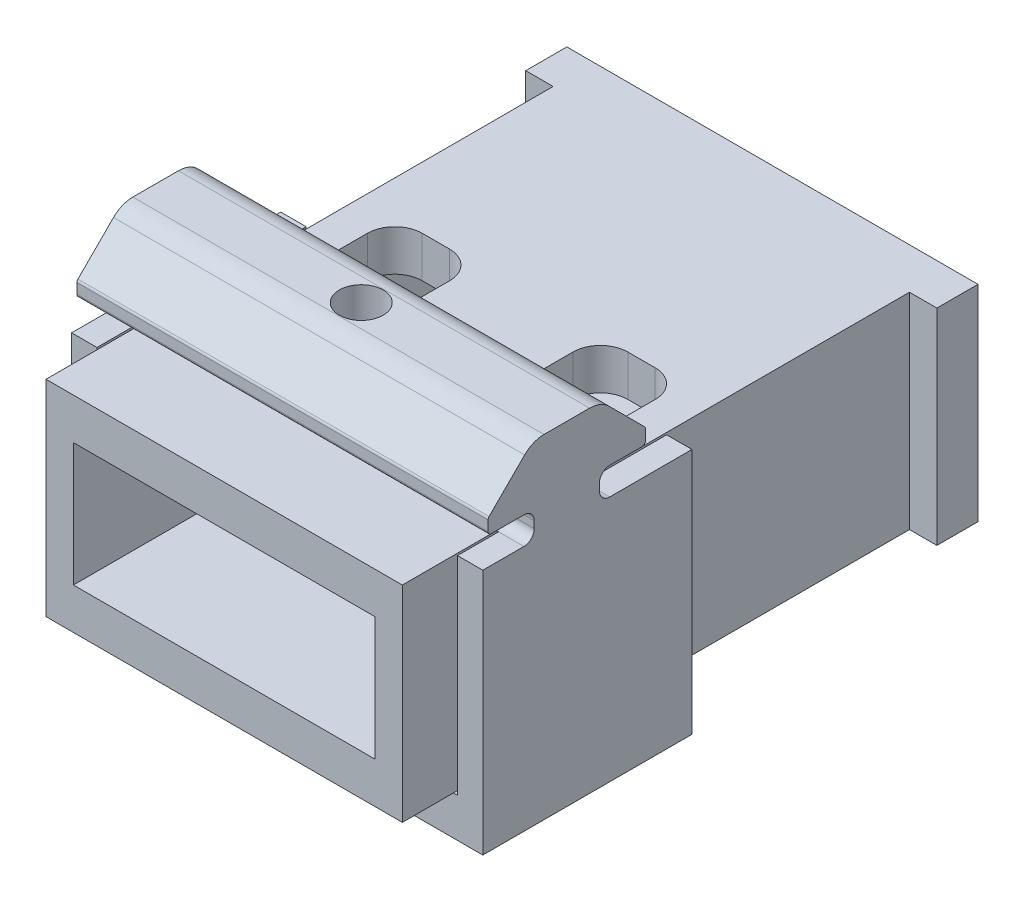
from build123d import *

# Parameters (mm, degrees)
BOSS_EXTRUDE1_DEPTH    = 15
SKETCH2_W              = 22
SKETCH2_H              = 9
CUT_EXTRUDE1_DEPTH     = 60.384867601
SKETCH4_R              = 1.2
CUT_EXTRUDE3_DEPTH     = 3
FILLET1_R              = 2
SPLIT1_SURFACE_1_BACK  = 55.366
SPLIT1_SURFACE_1_DEPTH = 110.732
SPLIT1_SURFACE_2_BACK  = 55.366
SPLIT1_SURFACE_2_DEPTH = 110.732
CUT_EXTRUDE2_START     = -29.25
CUT_EXTRUDE2_DEPTH     = 3
SKETCH6_R              = 1.6
CUT_EXTRUDE4_DEPTH     = 48.755722432
SKETCH10_W             = 2
SKETCH10_H             = 37
CUT_EXTRUDE6_DEPTH     = 15
BOSS_EXTRUDE2_START    = -6.87
BOSS_EXTRUDE2_DEPTH    = 6.26
BOSS_EXTRUDE4_DEPTH    = 3
BOSS_EXTRUDE5_START    = -6.26
BOSS_EXTRUDE5_DEPTH    = 6
SKETCH12_R             = 1
CUT_EXTRUDE7_DEPTH     = 2.85


with BuildPart() as part:
    # Sketch1 → Boss-Extrude1 (new, symmetric)
    with BuildSketch(Plane(origin=(0, 0, 0), x_dir=(0, 0, -1), z_dir=(1, 0, 0))):
        with BuildLine():
            Line((19.5, -26.25), (40, -26.25))
            Line((40, -26.25), (40, -41.25))
            Line((40, -41.25), (0, -41.25))
            Line((0, -41.25), (0, -26.25))
            Line((0, -26.25), (0.5, -26.25))
            Line((0.5, -26.25), (6.87, -26.25))
            ThreePointArc((6.87, -26.25), (7.400330086, -26.030330086), (7.62, -25.5))
            Line((7.62, -25.5), (7.62, -25))
            ThreePointArc((7.62, -25), (7.400330086, -24.469669914), (6.87, -24.25))
            Line((6.87, -24.25), (4.505, -24.25))
            ThreePointArc((4.505, -24.25), (4.328223305, -24.176776695), (4.255, -24))
            Line((4.255, -24), (4.255, -23.262766953))
            ThreePointArc((4.255, -23.262766953), (4.274030117, -23.167096095), (4.328223305, -23.085990258))
            Line((4.328223305, -23.085990258), (7.509213562, -19.905))
            Line((7.509213562, -19.905), (12.490786438, -19.905))
            Line((12.490786438, -19.905), (15.671776695, -23.085990258))
            ThreePointArc((15.671776695, -23.085990258), (15.725969883, -23.167096095), (15.745, -23.262766953))
            Line((15.745, -23.262766953), (15.745, -24))
            ThreePointArc((15.745, -24), (15.671776695, -24.176776695), (15.495, -24.25))
            Line((15.495, -24.25), (13.13, -24.25))
            ThreePointArc((13.13, -24.25), (12.599669914, -24.469669914), (12.38, -25))
            Line((12.38, -25), (12.38, -25.5))
            ThreePointArc((12.38, -25.5), (12.599669914, -26.030330086), (13.13, -26.25))
            Line((13.13, -26.25), (19.5, -26.25))
        make_face()
    extrude(amount=BOSS_EXTRUDE1_DEPTH, both=True)

    # Sketch2 → Cut-Extrude1 (cut, through all)
    with BuildSketch(Plane(origin=(0, 0, -40), x_dir=(-1, 0, 0), z_dir=(0, 0, -1))):
        with Locations((0, -33.75)):
            Rectangle(SKETCH2_W, SKETCH2_H)
    extrude(amount=-CUT_EXTRUDE1_DEPTH, mode=Mode.SUBTRACT)

    # Sketch4 → Cut-Extrude3 (cut)
    with BuildSketch(Plane(origin=(0, -38.25, 0), x_dir=(1, 0, 0), z_dir=(0, 1, 0))):
        with Locations(Location((-7.5, 19.15, 0), (0, 0, 270))):
            Circle(SKETCH4_R)
        with Locations(Location((7.5, 19.15, 0), (0, 0, 270))):
            Circle(SKETCH4_R)
    extrude(amount=-CUT_EXTRUDE3_DEPTH, mode=Mode.SUBTRACT)

    # Fillet1
    fillet1_edges = [part.edges().sort_by_distance(p)[0] for p in [
        (0, -19.905, -7.509213562),
        (0, -19.905, -12.490786438),
    ]]
    fillet(fillet1_edges, radius=FILLET1_R)


with BuildPart() as body_2:
    # Split1: the piece behind the surface
    add(part.part)
    # Split1 surface: a surface, the sketch's curves swept straight by 110.732 mm
    with BuildLine(Plane(origin=(15, 0, 0), x_dir=(0, 0, -1), z_dir=(1, 0, 0)).offset(-SPLIT1_SURFACE_1_BACK), mode=Mode.PRIVATE) as split1_surface_1_path:
        Line((0, -26.25), (40, -26.25))
    split1_surface_1 = Shell.extrude(split1_surface_1_path.wire(), (1 * SPLIT1_SURFACE_1_DEPTH, 0 * SPLIT1_SURFACE_1_DEPTH, 0 * SPLIT1_SURFACE_1_DEPTH))
    split(bisect_by=split1_surface_1, keep=Keep.BOTTOM)

    # Sketch3 → Cut-Extrude2 (cut)
    with BuildSketch(Plane(origin=(0, 0, 0), x_dir=(1, 0, 0), z_dir=(0, 1, 0)).offset(CUT_EXTRUDE2_START)):
        with BuildLine():
            Line((-10.5, 20.95), (-10.5, 14.95))
            ThreePointArc((-10.5, 14.95), (-9.914213562, 13.535786438), (-8.5, 12.95))
            Line((-8.5, 12.95), (-6.5, 12.95))
            ThreePointArc((-6.5, 12.95), (-5.085786438, 13.535786438), (-4.5, 14.95))
            Line((-4.5, 14.95), (-4.5, 20.95))
            ThreePointArc((-4.5, 20.95), (-5.085786438, 22.364213562), (-6.5, 22.95))
            Line((-6.5, 22.95), (-8.5, 22.95))
            ThreePointArc((-8.5, 22.95), (-9.914213562, 22.364213562), (-10.5, 20.95))
        make_face()
        with BuildLine():
            Line((10.5, 14.95), (10.5, 20.95))
            ThreePointArc((10.5, 20.95), (9.914213562, 22.364213562), (8.5, 22.95))
            Line((8.5, 22.95), (6.5, 22.95))
            ThreePointArc((6.5, 22.95), (5.085786438, 22.364213562), (4.5, 20.95))
            Line((4.5, 20.95), (4.5, 14.95))
            ThreePointArc((4.5, 14.95), (5.085786438, 13.535786438), (6.5, 12.95))
            Line((6.5, 12.95), (8.5, 12.95))
            ThreePointArc((8.5, 12.95), (9.914213562, 13.535786438), (10.5, 14.95))
        make_face()
    extrude(amount=CUT_EXTRUDE2_DEPTH, mode=Mode.SUBTRACT)

    # Sketch10 → Cut-Extrude6 (cut)
    with BuildSketch(Plane.XZ.offset(41.25)):
        with Locations((-14, -18.5)):
            Rectangle(SKETCH10_W, SKETCH10_H)
        with Locations((14, -18.5)):
            Rectangle(SKETCH10_W, SKETCH10_H)
    extrude(amount=-CUT_EXTRUDE6_DEPTH, mode=Mode.SUBTRACT)


with BuildPart() as part_1:
    add(part.part)

    # Split1: split by a surface, the side it looks to stays
    # Split1 surface: a surface, the sketch's curves swept straight by 110.732 mm
    with BuildLine(Plane(origin=(15, 0, 0), x_dir=(0, 0, -1), z_dir=(1, 0, 0)).offset(-SPLIT1_SURFACE_2_BACK), mode=Mode.PRIVATE) as split1_surface_2_path:
        Line((0, -26.25), (40, -26.25))
    split1_surface_2 = Shell.extrude(split1_surface_2_path.wire(), (1 * SPLIT1_SURFACE_2_DEPTH, 0 * SPLIT1_SURFACE_2_DEPTH, 0 * SPLIT1_SURFACE_2_DEPTH))
    split(bisect_by=split1_surface_2, keep=Keep.TOP)

    # Sketch6 → Cut-Extrude4 (cut, through all)
    with BuildSketch(Plane(origin=(0, -19.905, 0), x_dir=(1, 0, 0), z_dir=(0, 1, 0))):
        with Locations(Location((0, 10, 0), (0, 0, 270))):
            Circle(SKETCH6_R)
    extrude(amount=-CUT_EXTRUDE4_DEPTH, mode=Mode.SUBTRACT)

    # Sketch11 → Boss-Extrude2 (add)
    with BuildSketch(Plane.XY.offset(BOSS_EXTRUDE2_START)):
        Polygon((-13.15, -26.25), (-15, -26.25), (-15, -44.25), (15, -44.25), (15, -26.25), (13.15, -26.25), (13.15, -41.4), (-13.15, -41.4), align=None)
    extrude(amount=-BOSS_EXTRUDE2_DEPTH)

    # Sketch13 → Boss-Extrude4 (add)
    with BuildSketch(Plane.XY.offset(-6.87)):
        Polygon((13.15, -26.25), (13.15, -41.4), (-13.15, -41.4), (-13.15, -26.25), (-15, -26.25), (-15, -44.25), (15, -44.25), (15, -26.25), align=None)
    extrude(amount=BOSS_EXTRUDE4_DEPTH)

    # Sketch13_2 → Boss-Extrude5 (add)
    with BuildSketch(Plane.XY.offset(-6.87).offset(BOSS_EXTRUDE5_START)):
        Polygon((13.15, -26.25), (13.15, -41.4), (-13.15, -41.4), (-13.15, -26.25), (-15, -26.25), (-15, -44.25), (15, -44.25), (15, -26.25), align=None)
    extrude(amount=-BOSS_EXTRUDE5_DEPTH)

    # Sketch12 → Cut-Extrude7 (cut)
    with BuildSketch(Plane.XZ.offset(44.25)):
        with Locations(Location((0, -7.685, 0), (0, 0, 270))):
            Circle(SKETCH12_R)
        with Locations(Location((0, -15.315, 0), (0, 0, 270))):
            Circle(SKETCH12_R)
    extrude(amount=-CUT_EXTRUDE7_DEPTH, mode=Mode.SUBTRACT)


solid = Compound([body_2.part, part_1.part])
